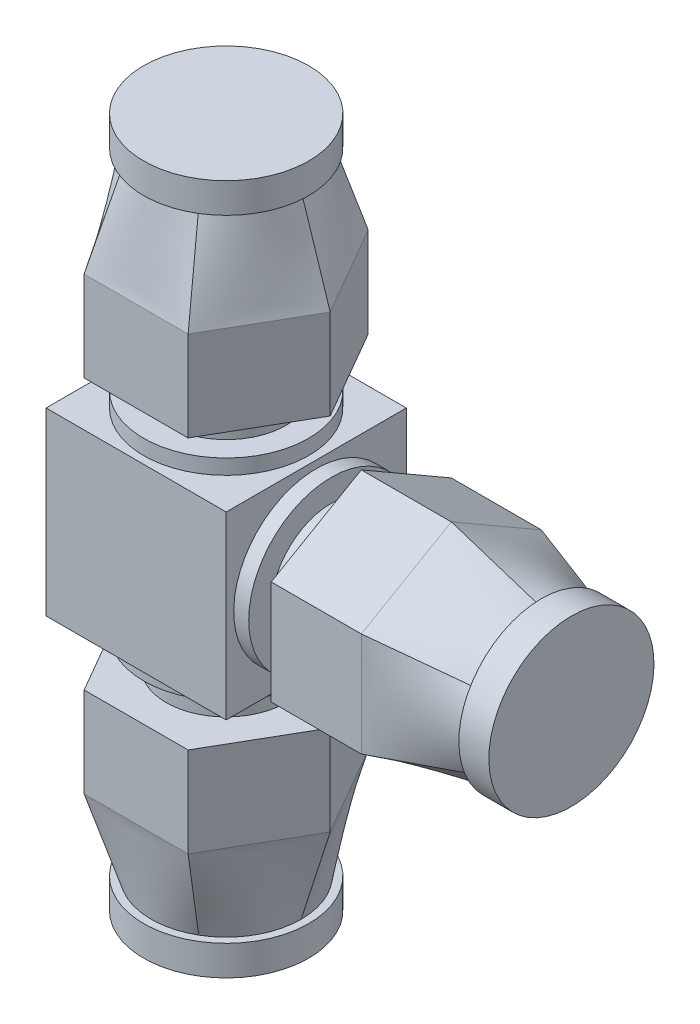
from build123d import *

# Parameters (mm, degrees)
SZKIC1_W                    = 12
SZKIC1_H                    = 12
DODANIE_WYCI_GNI_CIE1_DEPTH = 12
SZKIC2_R                    = 5.5
DODANIE_WYCI_GNI_CIE2_DEPTH = 1
SZKIC3_R                    = 4
DODANIE_WYCI_GNI_CIE3_DEPTH = 2
SZKIC4_R                    = 4
DODANIE_WYCI_GNI_CIE4_DEPTH = 6
SZKIC7_R                    = 5.5
DODANIE_WYCI_GNI_CIE5_DEPTH = 2
SZKIC8_R                    = 5.5
DODANIE_WYCI_GNI_CIE6_DEPTH = 1
SZKIC9_R                    = 4
DODANIE_WYCI_GNI_CIE7_DEPTH = 2
DODANIE_WYCI_GNI_CIE8_DEPTH = 6
SZKIC13_R                   = 5.5
DODANIE_WYCI_GNI_CIE9_DEPTH = 2


with BuildPart() as part:
    # Szkic1 → Dodanie-wyciągnięcie1 (new body)
    with BuildSketch(Plane.XY):
        with Locations((6, 0)):
            Rectangle(SZKIC1_W, SZKIC1_H)
    extrude(amount=DODANIE_WYCI_GNI_CIE1_DEPTH)

    # Szkic2 → Dodanie-wyciągnięcie2 (add)
    with BuildSketch(Plane.XZ.offset(6)):
        with Locations(Location((6, 6, 0), (0, 0, 90))):
            Circle(SZKIC2_R)
    dodanie_wyci_gni_cie2 = extrude(amount=DODANIE_WYCI_GNI_CIE2_DEPTH)

    # Szkic3 → Dodanie-wyciągnięcie3 (add)
    with BuildSketch(Plane.XZ.offset(7)):
        with Locations(Location((6, 6, 0), (0, 0, 270))):
            Circle(SZKIC3_R)
    dodanie_wyci_gni_cie3 = extrude(amount=DODANIE_WYCI_GNI_CIE3_DEPTH)

    # Szkic4 → Dodanie-wyciągnięcie4 (add)
    with BuildSketch(Plane.XZ.offset(9)):
        Polygon((9.464101615, 0), (12.92820323, 6), (9.464101615, 12), (2.535898385, 12), (-0.92820323, 6), (2.535898385, 0), align=None)
        with Locations(Location((6, 6, 0), (0, 0, 270))):
            Circle(SZKIC4_R, mode=Mode.SUBTRACT)
        with Locations(Location((6, 6, 0), (0, 0, 270))):
            Circle(SZKIC4_R)
    dodanie_wyci_gni_cie4 = extrude(amount=DODANIE_WYCI_GNI_CIE4_DEPTH)

    # Szkic5 for Wyci_gni_cie → Wyciągnięcie po profilach1 section 0
    with BuildSketch(Plane(origin=(0, -21, 0), x_dir=(-1, 0, 0), z_dir=(0, -1, 0))):
        with BuildLine():
            # circular arc as an exact rational Bezier (weights 1, cos(half-angle), 1)
            Bezier((-8.5, -1.669872981), (-11, -3.113248654), (-11, -6), weights=[1, 0.866025404, 1])
            Bezier((-11, -6), (-11, -8.886751346), (-8.5, -10.330127019), weights=[1, 0.866025404, 1])
            Bezier((-8.5, -10.330127019), (-6, -11.773502692), (-3.5, -10.330127019), weights=[1, 0.866025404, 1])
            Bezier((-3.5, -10.330127019), (-1, -8.886751346), (-1, -6), weights=[1, 0.866025404, 1])
            Bezier((-1, -6), (-1, -3.113248654), (-3.5, -1.669872981), weights=[1, 0.866025404, 1])
            Bezier((-3.5, -1.669872981), (-6, -0.226497308), (-8.5, -1.669872981), weights=[1, 0.866025404, 1])
        make_face()
    # Szkic6 → Wyciągnięcie po profilach1 section 1
    with BuildSketch(Plane.XZ.offset(15)):
        Polygon((9.464101615, 0), (12.92820323, 6), (9.464101615, 12), (2.535898385, 12), (-0.92820323, 6), (2.535898385, 0), align=None)
    wyci_gni_cie_po_profilach1 = loft()

    # Szkic7 → Dodanie-wyciągnięcie5 (add)
    with BuildSketch(Plane.XZ.offset(21)):
        with Locations(Location((6, 6, 0), (0, 0, 90))):
            Circle(SZKIC7_R)
    dodanie_wyci_gni_cie5 = extrude(amount=DODANIE_WYCI_GNI_CIE5_DEPTH)

    # Lustro1: Dodanie-wyciągnięcie2, Dodanie-wyciągnięcie3, Dodanie-wyciągnięcie4, Wyciągnięcie po profilach1, Dodanie-wyciągnięcie5 across plane
    add(dodanie_wyci_gni_cie2.mirror(Plane.ZX))
    add(dodanie_wyci_gni_cie3.mirror(Plane.ZX))
    add(dodanie_wyci_gni_cie4.mirror(Plane.ZX))
    add(wyci_gni_cie_po_profilach1.mirror(Plane.ZX))
    add(dodanie_wyci_gni_cie5.mirror(Plane.ZX))

    # Szkic8 → Dodanie-wyciągnięcie6 (add)
    with BuildSketch(Plane(origin=(12, 0, 0), x_dir=(0, 0, -1), z_dir=(1, 0, 0))):
        with Locations(Location((-6, 0, 0), (0, 0, 270))):
            Circle(SZKIC8_R)
    extrude(amount=DODANIE_WYCI_GNI_CIE6_DEPTH)

    # Szkic9 → Dodanie-wyciągnięcie7 (add)
    with BuildSketch(Plane(origin=(13, 0, 0), x_dir=(0, 0, -1), z_dir=(1, 0, 0))):
        with Locations(Location((-6, 0, 0), (0, 0, 90))):
            Circle(SZKIC9_R)
    extrude(amount=DODANIE_WYCI_GNI_CIE7_DEPTH)

    # Szkic10 → Dodanie-wyciągnięcie8 (add)
    with BuildSketch(Plane(origin=(15, 0, 0), x_dir=(0, 0, -1), z_dir=(1, 0, 0))):
        Polygon((-6, 6.92820323), (-12, 3.464101615), (-12, -3.464101615), (-6, -6.92820323), (0, -3.464101615), (0, 3.464101615), align=None)
    extrude(amount=DODANIE_WYCI_GNI_CIE8_DEPTH)

    # Szkic12 → Wyciągnięcie po profilach2 section 0
    with BuildSketch(Plane(origin=(21, 0, 0), x_dir=(0, 0, -1), z_dir=(1, 0, 0))):
        Polygon((0, 3.464101615), (-6, 6.92820323), (-12, 3.464101615), (-12, -3.464101615), (-6, -6.92820323), (0, -3.464101615), align=None)
    # Szkic11 for Wyci_gni_cie → Wyciągnięcie po profilach2 section 1
    with BuildSketch(Plane(origin=(27, 0, 0), x_dir=(0, 0, -1), z_dir=(1, 0, 0))):
        with BuildLine():
            Bezier((-1.669872981, 2.5), (-3.113248654, 5), (-6, 5), weights=[1, 0.866025404, 1])
            Bezier((-6, 5), (-8.886751346, 5), (-10.330127019, 2.5), weights=[1, 0.866025404, 1])
            Bezier((-10.330127019, 2.5), (-11.773502692, 0), (-10.330127019, -2.5), weights=[1, 0.866025404, 1])
            Bezier((-10.330127019, -2.5), (-8.886751346, -5), (-6, -5), weights=[1, 0.866025404, 1])
            Bezier((-6, -5), (-3.113248654, -5), (-1.669872981, -2.5), weights=[1, 0.866025404, 1])
            Bezier((-1.669872981, -2.5), (-0.226497308, 0), (-1.669872981, 2.5), weights=[1, 0.866025404, 1])
        make_face()
    loft()

    # Szkic13 → Dodanie-wyciągnięcie9 (add)
    with BuildSketch(Plane(origin=(27, 0, 0), x_dir=(0, 0, -1), z_dir=(1, 0, 0))):
        with Locations(Location((-6, 0, 0), (0, 0, 270))):
            Circle(SZKIC13_R)
    extrude(amount=DODANIE_WYCI_GNI_CIE9_DEPTH)


solid = part.part
